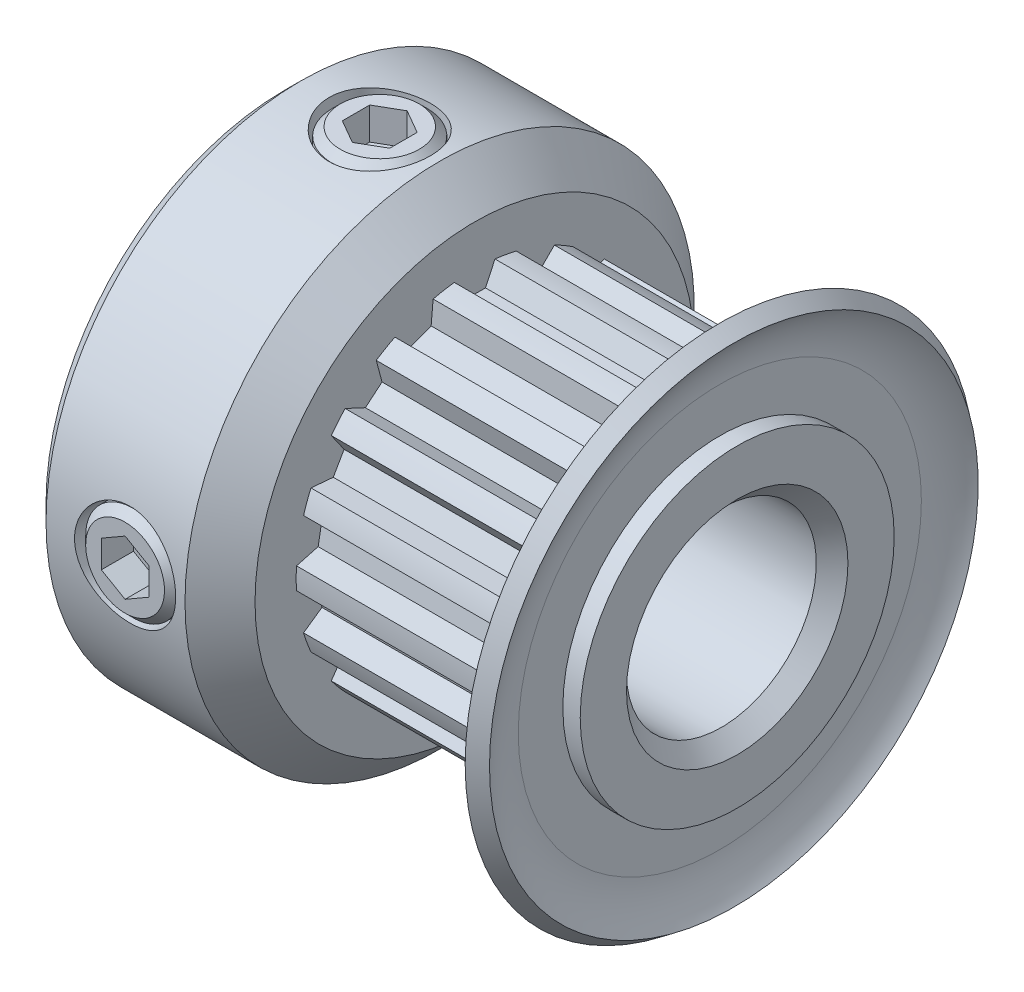
from build123d import *

# Parameters (mm, degrees)
SKETCH4_R          = 5.8
SKETCH4_R_2        = 5.64125
CUT_EXTRUDE2_DEPTH = 7.2
CUT_EXTRUDE1_DEPTH = 7.2
CIRPATTERN1_COUNT  = 18
SKETCH6_R          = 1.6
CUT_EXTRUDE3_DEPTH = 14.44349285
CUT_EXTRUDE4_DEPTH = 1.016
CIRPATTERN2_COUNT  = 2
CIRPATTERN2_ANGLE  = 90
CIRPATTERN3_COUNT  = 2
CIRPATTERN3_ANGLE  = 90
CHAMFER1_SIZE      = 0.5


with BuildPart() as part:
    # Sketch1 → Revolve1 (revolve)
    with BuildSketch(Plane.XY, mode=Mode.PRIVATE) as revolve1_sk:
        with BuildLine():
            Line((-7.15, 3), (7.15, 3))
            Line((7.15, 3), (7.15, 8.05))
            Line((7.15, 8.05), (6.6, 8.05))
            ThreePointArc((6.6, 8.05), (6.19100507, 7.25465659), (6.05, 6.3715))
            Line((6.05, 6.3715), (6.05, 5.8))
            Line((6.05, 5.8), (-1.15, 5.8))
            Line((-1.15, 5.8), (-1.15, 6.943))
            Line((-1.15, 6.943), (-2.257, 8.05))
            Line((-2.257, 8.05), (-7.15, 8.05))
            Line((-7.15, 8.05), (-7.15, 3))
        make_face()
    revolve(revolve1_sk.sketch.rotate(Axis((-7.15, 0, 0), (1, 0, 0)), 90), axis=Axis((-7.15, 0, 0), (1, 0, 0)))

    # Sketch4 → Cut-Extrude2 (cut)
    with BuildSketch(Plane(origin=(-1.15, 0, 0), x_dir=(0, 0, -1), z_dir=(1, 0, 0))):
        Circle(SKETCH4_R)
        Circle(SKETCH4_R_2, mode=Mode.SUBTRACT)
    extrude(amount=CUT_EXTRUDE2_DEPTH, mode=Mode.SUBTRACT)

    # Sketch3 → Cut-Extrude1 (cut)
    with BuildSketch(Plane(origin=(-1.15, 0, 0), x_dir=(0, 0, -1), z_dir=(1, 0, 0))):
        with BuildLine():
            Line((-0.642345316, 5.604560113), (-0.343021997, 4.962659182))
            Line((-0.343021997, 4.962659182), (0.343021997, 4.962659182))
            Line((0.343021997, 4.962659182), (0.642345316, 5.604560113))
            ThreePointArc((0.642345316, 5.604560113), (0, 5.64125), (-0.642345316, 5.604560113))
        make_face()
    cut_extrude1 = extrude(amount=CUT_EXTRUDE1_DEPTH, mode=Mode.SUBTRACT)

    # CirPattern1: Cut-Extrude1 ×18 about axis
    cirpattern1_axis = Axis((0, 0, 0), (1, 0, 0))
    for i in range(1, CIRPATTERN1_COUNT):
        add(cut_extrude1.rotate(cirpattern1_axis, i * 360 / CIRPATTERN1_COUNT), mode=Mode.SUBTRACT)

    # Sketch6 → Cut-Extrude3 (cut, through all)
    with BuildSketch(Plane(origin=(0, 0, 0), x_dir=(1, 0, 0), z_dir=(0, 1, 0))):
        with Locations(Location((-4.15, 0, 0), (0, 0, 90))):
            Circle(SKETCH6_R)
    cut_extrude3 = extrude(amount=CUT_EXTRUDE3_DEPTH, mode=Mode.SUBTRACT)

    # CirPattern2: Cut-Extrude3 ×2 about axis
    cirpattern2_axis = Axis((-7.15, 0, 0), (1, 0, 0))
    for i in range(1, CIRPATTERN2_COUNT):
        add(cut_extrude3.rotate(cirpattern2_axis, i * CIRPATTERN2_ANGLE / (CIRPATTERN2_COUNT - 1)), mode=Mode.SUBTRACT)

    # Chamfer1
    chamfer1_edges = [part.edges().sort_by_distance(p)[0] for p in [
        (-7.15, 0, -8.05),
        (-7.15, 0, -3),
        (7.15, 0, -3),
    ]]
    chamfer(chamfer1_edges, length=CHAMFER1_SIZE)

    # Sketch9 → Cut-Revolve1 (revolve, cut)
    with BuildSketch(Plane.XY, mode=Mode.PRIVATE) as cut_revolve1_sk:
        with BuildLine():
            Line((7.15, 4.962659182), (7.15, 8.05))
            Line((7.15, 8.05), (6.79262822, 8.312373569))
            Line((6.79262822, 8.312373569), (6.6, 8.05))
            Line((6.6, 8.05), (7.04334465, 7.724507264))
            ThreePointArc((7.04334465, 7.724507264), (6.713661534, 7.083395908), (6.6, 6.3715))
            Line((6.6, 6.3715), (6.6, 4.962659182))
            Line((6.6, 4.962659182), (7.15, 4.962659182))
        make_face()
    revolve(cut_revolve1_sk.sketch.rotate(Axis((-7.15, 0, 0), (1, 0, 0)), 90), axis=Axis((-7.15, 0, 0), (1, 0, 0)), mode=Mode.SUBTRACT)


with BuildPart() as body_2:
    # Sketch7 → Revolve2 (revolve)
    with BuildSketch(Plane.XY, mode=Mode.PRIVATE) as revolve2_sk:
        Polygon((-5.396, 8.05), (-4.15, 8.05), (-4.15, 3.381), (-5.396, 3.381), (-5.65, 3.635), (-5.65, 7.796), align=None)
    revolve(revolve2_sk.sketch.rotate(Axis((-4.15, 3.381, 0), (0, 1, 0)), 270), axis=Axis((-4.15, 3.381, 0), (0, 1, 0)))

    # Sketch8 → Cut-Extrude4 (cut)
    with BuildSketch(Plane(origin=(0, 8.05, 0), x_dir=(1, 0, 0), z_dir=(0, 1, 0))):
        Polygon((-4.15, 0.866025404), (-4.9, 0.433012702), (-4.9, -0.433012702), (-4.15, -0.866025404), (-3.4, -0.433012702), (-3.4, 0.433012702), align=None)
    extrude(amount=-CUT_EXTRUDE4_DEPTH, mode=Mode.SUBTRACT)


with BuildPart() as cirpattern3_1:
    # CirPattern3: pattern copy
    add(body_2.part.rotate(Axis((0, 0, 0), (1, 0, 0)), 1 * CIRPATTERN3_ANGLE / (CIRPATTERN3_COUNT - 1)))


solid = Compound([part.part, body_2.part, cirpattern3_1.part])
